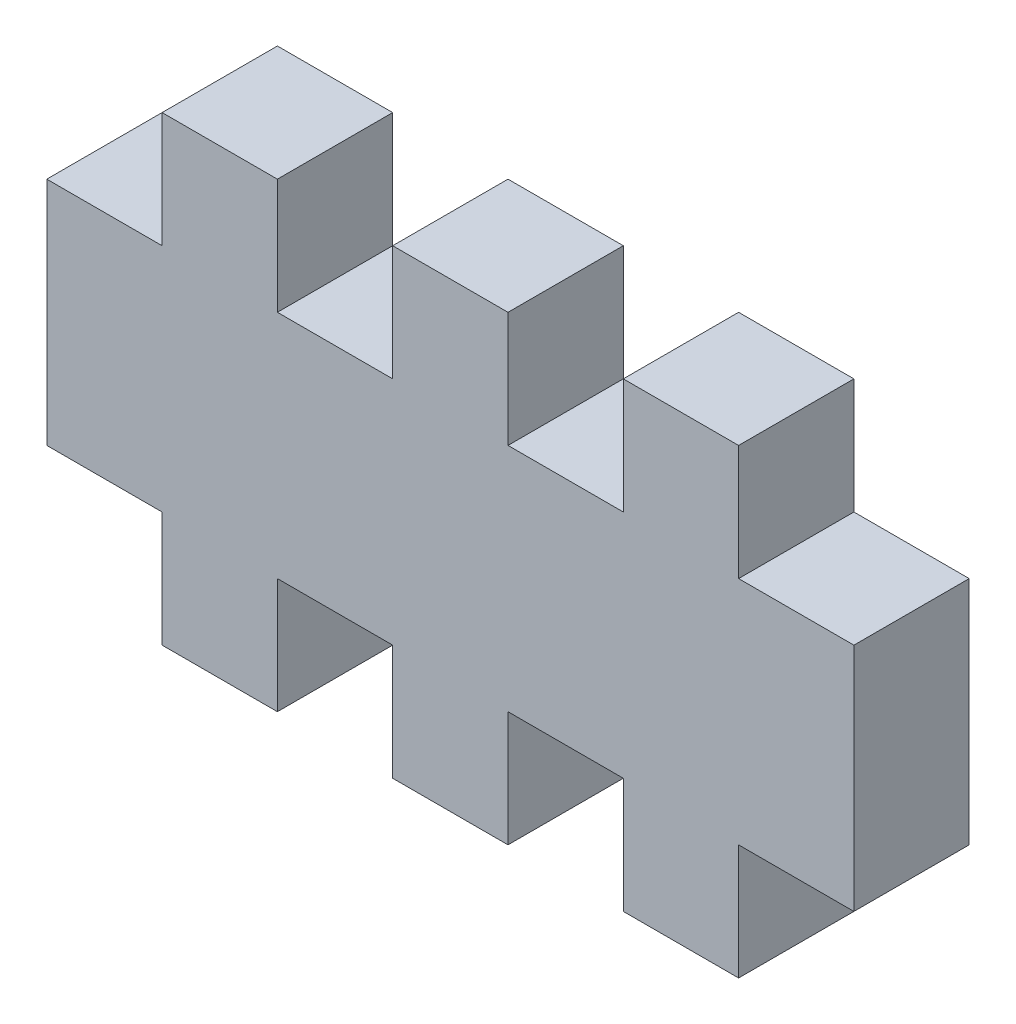
from build123d import *

# Parameters (mm, degrees)
BOSS_EXTRU_1_DEPTH = 3


with BuildPart() as part:
    # Esquisse1 → Boss.-Extru.1 (new body)
    with BuildSketch(Plane.XY):
        Polygon((9, 9), (9, 6), (6, 6), (6, 9), (3, 9), (3, 6), (0, 6), (0, 0), (3, 0), (3, -3), (6, -3), (6, 0), (9, 0), (9, -3), (12, -3), (12, 0), (15, 0), (15, -3), (18, -3), (18, 0), (21, 0), (21, 6), (18, 6), (18, 9), (15, 9), (15, 6), (12, 6), (12, 9), align=None)
    extrude(amount=BOSS_EXTRU_1_DEPTH)


solid = part.part
